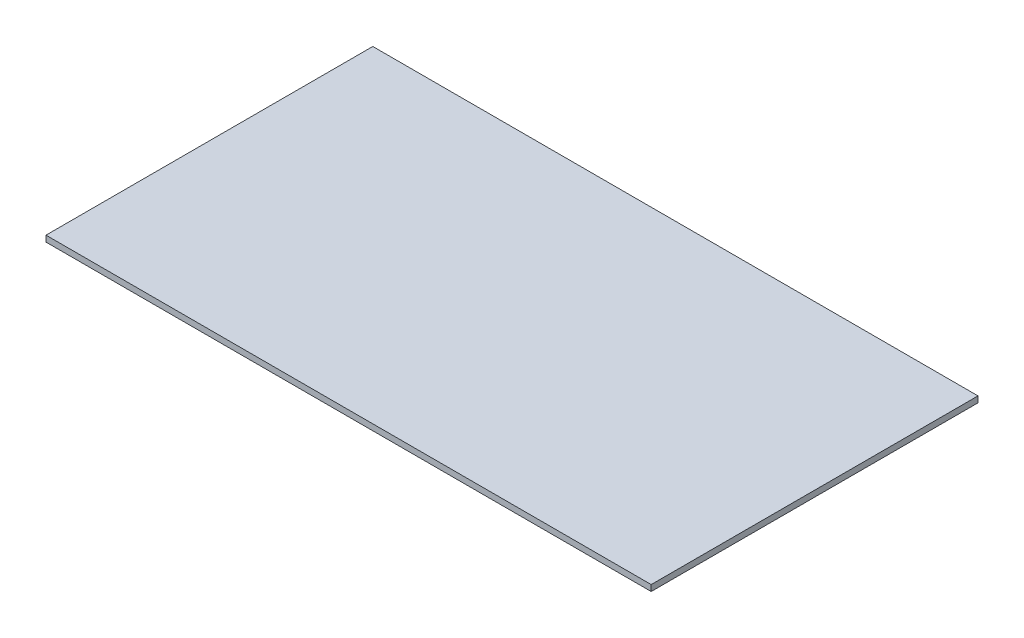
from build123d import *

# Parameters (mm, degrees)
SKETCH1_W           = 1000
SKETCH1_H           = 540
BOSS_EXTRUDE1_DEPTH = 10


with BuildPart() as part:
    # Sketch1 → Boss-Extrude1 (new body)
    with BuildSketch(Plane(origin=(0, 0, 0), x_dir=(1, 0, 0), z_dir=(0, 1, 0))):
        Rectangle(SKETCH1_W, SKETCH1_H)
    extrude(amount=BOSS_EXTRUDE1_DEPTH)


solid = part.part
